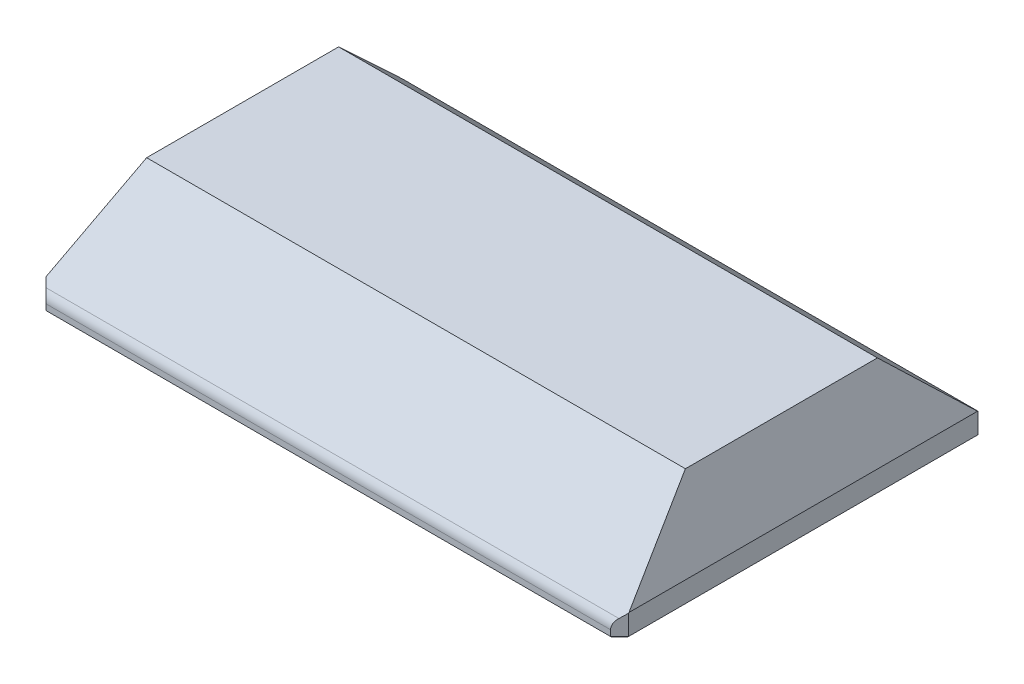
from build123d import *

# Parameters (mm, degrees)
SKETCH1_W               = 130
SKETCH1_H               = 82
BOSS_EXTRUDE1_DEPTH     = 5
SKETCH3_W               = 130
SKETCH3_H               = 82
SKETCH2_W               = 120
SKETCH2_H               = 46
CHAMFER1_SIZE           = 2
SKETCH4_R               = 1.2
CUT_EXTRUDE1_DEPTH      = 4
SKETCH5_W               = 114
SKETCH5_H               = 40
CUT_EXTRUDE2_DEPTH      = 21
SKETCH6_W               = 118
SKETCH6_H               = 56
CUT_EXTRUDE3_DEPTH      = 12
SKETCH8_W               = 7
SKETCH8_H               = 7
BOSS_EXTRUDE2_DEPTH     = 8
SKETCH9_R               = 2.1
CUT_EXTRUDE4_DEPTH      = 8
SKETCH10_W              = 2
SKETCH10_H              = 40
CUT_EXTRUDE5_DEPTH      = 9
CUT_EXTRUDE6_DEPTH      = 66.0000001
CUT_EXTRUDE6_DEPTH_BACK = 66.0000001
SKETCH12_W              = 82
SKETCH12_H              = 2
CUT_EXTRUDE7_DEPTH      = 66.0000001
CUT_EXTRUDE7_DEPTH_BACK = 66.0000001
FILLET1_R               = 3
CHAMFER2_SIZE           = 0.4


with BuildPart() as part:
    # Sketch1 → Boss-Extrude1 (new body)
    with BuildSketch(Plane(origin=(0, 0, 0), x_dir=(1, 0, 0), z_dir=(0, 1, 0))):
        Rectangle(SKETCH1_W, SKETCH1_H)
    extrude(amount=BOSS_EXTRUDE1_DEPTH)

    # Sketch3 → Loft2 section 0
    with BuildSketch(Plane(origin=(0, 5, 0), x_dir=(1, 0, 0), z_dir=(0, 1, 0))):
        Rectangle(SKETCH3_W, SKETCH3_H)
    # Sketch2 → Loft2 section 1
    with BuildSketch(Plane(origin=(0, 22, 0), x_dir=(1, 0, 0), z_dir=(0, 1, 0))):
        Rectangle(SKETCH2_W, SKETCH2_H)
    loft()

    # Chamfer1
    chamfer1_edges = [part.edges().sort_by_distance(p)[0] for p in [
        (-65, 2.5, 41),
        (65, 2.5, 41),
        (65, 2.5, -41),
        (-65, 2.5, -41),
    ]]
    chamfer(chamfer1_edges, length=CHAMFER1_SIZE)

    # Sketch4 → Cut-Extrude1 (cut)
    with BuildSketch(Plane.XZ):
        with Locations((40, -37.5)):
            Circle(SKETCH4_R)
        with Locations((-40, -37.5)):
            Circle(SKETCH4_R)
    cut_extrude1 = extrude(amount=-CUT_EXTRUDE1_DEPTH, mode=Mode.SUBTRACT)

    # Sketch5 → Cut-Extrude2 (cut)
    with BuildSketch(Plane.XZ):
        Rectangle(SKETCH5_W, SKETCH5_H)
    extrude(amount=-CUT_EXTRUDE2_DEPTH, mode=Mode.SUBTRACT)

    # Mirror1: Cut-Extrude1 across plane
    add(cut_extrude1.mirror(Plane.XY), mode=Mode.SUBTRACT)

    # Sketch6 → Cut-Extrude3 (cut)
    with BuildSketch(Plane.XZ):
        Rectangle(SKETCH6_W, SKETCH6_H)
    extrude(amount=-CUT_EXTRUDE3_DEPTH, mode=Mode.SUBTRACT)

    # Sketch8 → Boss-Extrude2 (add)
    with BuildSketch(Plane(origin=(0, 4, 0), x_dir=(-1, 0, 0), z_dir=(0, -1, 0))):
        with Locations((-55.5, 24.5)):
            Rectangle(SKETCH8_W, SKETCH8_H)
        with Locations((-55.5, -24.5)):
            Rectangle(SKETCH8_W, SKETCH8_H)
        with Locations((55.5, -24.5)):
            Rectangle(SKETCH8_W, SKETCH8_H)
        with Locations((55.5, 24.5)):
            Rectangle(SKETCH8_W, SKETCH8_H)
    extrude(amount=-BOSS_EXTRUDE2_DEPTH)

    # Sketch9 → Cut-Extrude4 (cut)
    with BuildSketch(Plane.XZ.offset(-4)):
        with Locations((-55.5, 24.5)):
            Circle(SKETCH9_R)
        with Locations((55.5, 24.5)):
            Circle(SKETCH9_R)
        with Locations((55.5, -24.5)):
            Circle(SKETCH9_R)
        with Locations((-55.5, -24.5)):
            Circle(SKETCH9_R)
    extrude(amount=-CUT_EXTRUDE4_DEPTH, mode=Mode.SUBTRACT)

    # Sketch10 → Cut-Extrude5 (cut)
    with BuildSketch(Plane.XZ.offset(-12)):
        with Locations((-58, 0)):
            Rectangle(SKETCH10_W, SKETCH10_H)
        with Locations((58, 0)):
            Rectangle(SKETCH10_W, SKETCH10_H)
    extrude(amount=-CUT_EXTRUDE5_DEPTH, mode=Mode.SUBTRACT)

    # Sketch11 → Cut-Extrude6 (cut, two sides)
    with BuildSketch(Plane(origin=(0, 0, 0), x_dir=(0, 0, -1), z_dir=(1, 0, 0))) as cut_extrude6_sk:
        Polygon((21, 22), (41, 3), (41, 5), (23, 22), align=None)
        Polygon((-23, 22), (-21, 22), (-41, 3), (-41, 5), align=None)
    extrude(amount=CUT_EXTRUDE6_DEPTH, mode=Mode.SUBTRACT)
    extrude(cut_extrude6_sk.sketch, amount=-CUT_EXTRUDE6_DEPTH_BACK, mode=Mode.SUBTRACT)

    # Sketch12 → Cut-Extrude7 (cut, two sides)
    with BuildSketch(Plane(origin=(0, 0, 0), x_dir=(0, 0, -1), z_dir=(1, 0, 0))) as cut_extrude7_sk:
        with Locations((0, 22.6)):
            Rectangle(SKETCH12_W, SKETCH12_H)
    extrude(amount=CUT_EXTRUDE7_DEPTH, mode=Mode.SUBTRACT)
    extrude(cut_extrude7_sk.sketch, amount=-CUT_EXTRUDE7_DEPTH_BACK, mode=Mode.SUBTRACT)

    # Fillet1
    fillet1_edges = [part.edges().sort_by_distance(p)[0] for p in [
        (0, 3, -41),
        (0, 3, 41),
    ]]
    fillet(fillet1_edges, radius=FILLET1_R)

    # Chamfer2
    chamfer2_edges = [part.edges().sort_by_distance(p)[0] for p in [
        (0, 0, 41),
        (65, 0, 0),
        (-65, 0, 0),
        (0, 0, -41),
        (-64, 0, -40),
        (64, 0, -40),
        (64, 0, 40),
        (-64, 0, 40),
    ]]
    chamfer(chamfer2_edges, length=CHAMFER2_SIZE)


solid = part.part
